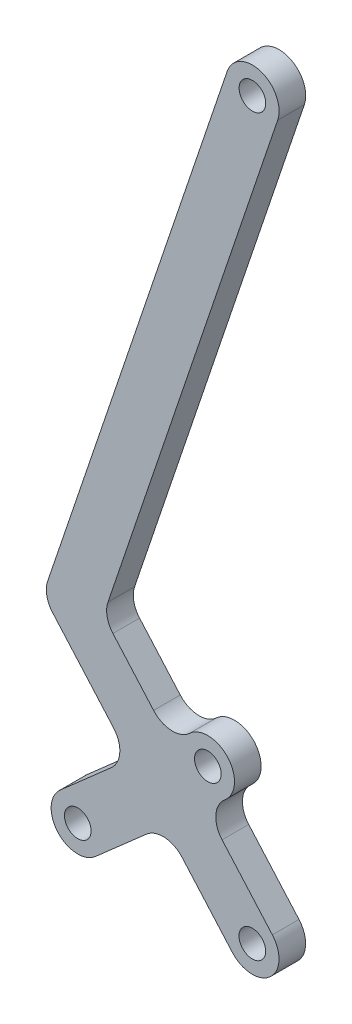
from build123d import *

# Parameters (mm, degrees)
SKETCH1_R           = 6.35
BOSS_EXTRUDE2_DEPTH = 12.7


with BuildPart() as part:
    # Sketch1 → Boss-Extrude2 (new body)
    with BuildSketch(Plane.XY):
        with BuildLine():
            Line((-12.031647615, 4.065643329), (-97.612603668, -249.198064906))
            ThreePointArc((-97.612603668, -249.198064906), (-98.010291731, -255.396978352), (-95.255242973, -260.964238904))
            Line((-95.255242973, -260.964238904), (-66.174198568, -294.032435491))
            ThreePointArc((-66.174198568, -294.032435491), (-63.209942623, -302.725331079), (-67.260702561, -310.968181978))
            Line((-67.260702561, -310.968181978), (-91.628287065, -332.397678599))
            ThreePointArc((-91.628287065, -332.397678599), (-92.778170458, -350.321343631), (-74.854505426, -351.471227024))
            Line((-74.854505426, -351.471227024), (-50.486920922, -330.041730403))
            ThreePointArc((-50.486920922, -330.041730403), (-41.794025334, -327.077474458), (-33.551174435, -331.128234397))
            Line((-33.551174435, -331.128234397), (-9.579195164, -358.386888249))
            ThreePointArc((-9.579195164, -358.386888249), (8.344469868, -359.536771642), (9.494353261, -341.61310661))
            Line((9.494353261, -341.61310661), (-14.47762601, -314.354452758))
            ThreePointArc((-14.47762601, -314.354452758), (-17.441881955, -305.66155717), (-13.391122016, -297.418706271))
            Line((-13.391122016, -297.418706271), (-12.865473044, -296.956436698))
            ThreePointArc((-12.865473044, -296.956436698), (-11.715589651, -279.032771666), (-29.639254683, -277.882888273))
            Line((-29.639254683, -277.882888273), (-30.164903655, -278.345157846))
            ThreePointArc((-30.164903655, -278.345157846), (-38.857799244, -281.309413791), (-47.100650142, -277.258653852))
            Line((-47.100650142, -277.258653852), (-66.497347204, -255.202575583))
            ThreePointArc((-66.497347204, -255.202575583), (-69.252395961, -249.635315031), (-68.854707898, -243.436401585))
            Line((-68.854707898, -243.436401585), (12.031647615, -4.065643329))
            ThreePointArc((12.031647615, -4.065643329), (4.065643329, 12.031647615), (-12.031647615, 4.065643329))
        make_face()
        with Locations((-21.252363864, -287.419662486)):
            Circle(SKETCH1_R, mode=Mode.SUBTRACT)
        with Locations((-83.241396246, -341.934452812)):
            Circle(SKETCH1_R, mode=Mode.SUBTRACT)
        with Locations((-0.042420952, -349.999997429)):
            Circle(SKETCH1_R, mode=Mode.SUBTRACT)
        Circle(SKETCH1_R, mode=Mode.SUBTRACT)
    extrude(amount=BOSS_EXTRUDE2_DEPTH)


solid = part.part
